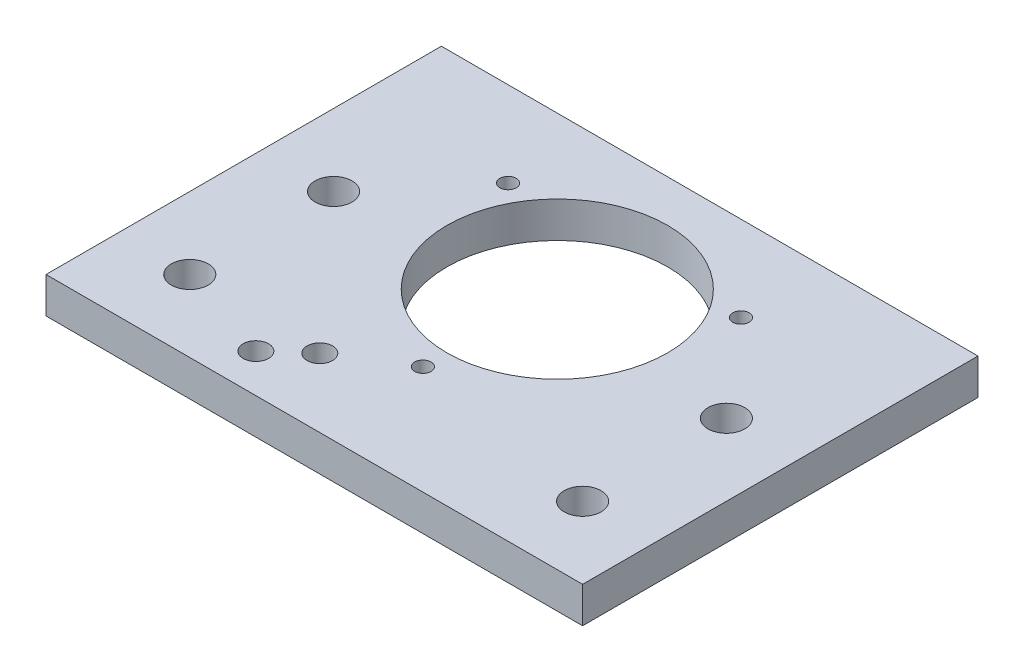
from build123d import *

# Parameters (mm, degrees)
SKETCH1_W           = 94.8
SKETCH1_H           = 69.85
SKETCH1_R           = 2.25
SKETCH1_R_2         = 1.45
SKETCH1_R_3         = 3.25755
SKETCH1_R_4         = 19.5
BOSS_EXTRUDE1_DEPTH = 6.35
CUT_EXTRUDE2_DEPTH  = 3


with BuildPart() as part:
    # Sketch1 → Boss-Extrude1 (new body)
    with BuildSketch(Plane(origin=(0, 0, 0), x_dir=(1, 0, 0), z_dir=(0, 1, 0))):
        Rectangle(SKETCH1_W, SKETCH1_H)
        with Locations((-17.138337536, -28.111820997)):
            Circle(SKETCH1_R, mode=Mode.SUBTRACT)
        with Locations((20.56810334, 19.875)):
            Circle(SKETCH1_R_2, mode=Mode.SUBTRACT)
        with Locations((-20.56810334, 19.875)):
            Circle(SKETCH1_R_2, mode=Mode.SUBTRACT)
        with Locations((0, -15.75)):
            Circle(SKETCH1_R_2, mode=Mode.SUBTRACT)
        with Locations((34.7, 3.175)):
            Circle(SKETCH1_R_3, mode=Mode.SUBTRACT)
        with Locations((-34.7, 3.175)):
            Circle(SKETCH1_R_3, mode=Mode.SUBTRACT)
        with Locations((0, 8)):
            Circle(SKETCH1_R_4, mode=Mode.SUBTRACT)
        with Locations((-11.164910261, -22.79033938)):
            Circle(SKETCH1_R, mode=Mode.SUBTRACT)
        with Locations((-34.7, -22.225)):
            Circle(SKETCH1_R_3, mode=Mode.SUBTRACT)
        with Locations((34.7, -22.225)):
            Circle(SKETCH1_R_3, mode=Mode.SUBTRACT)
    extrude(amount=BOSS_EXTRUDE1_DEPTH)

    # Sketch4 → Cut-Extrude2 (cut)
    with BuildSketch(Plane.XZ):
        with BuildLine():
            Line((-14.145004126, 31.471873838), (-8.171576852, 26.150392222))
            ThreePointArc((-8.171576852, 26.150392222), (-7.804857419, 19.797005971), (-14.15824367, 19.430286538))
            Line((-14.15824367, 19.430286538), (-20.131670945, 24.751768155))
            ThreePointArc((-20.131670945, 24.751768155), (-20.498390378, 31.105154406), (-14.145004126, 31.471873838))
        make_face()
    extrude(amount=-CUT_EXTRUDE2_DEPTH, mode=Mode.SUBTRACT)


solid = part.part
